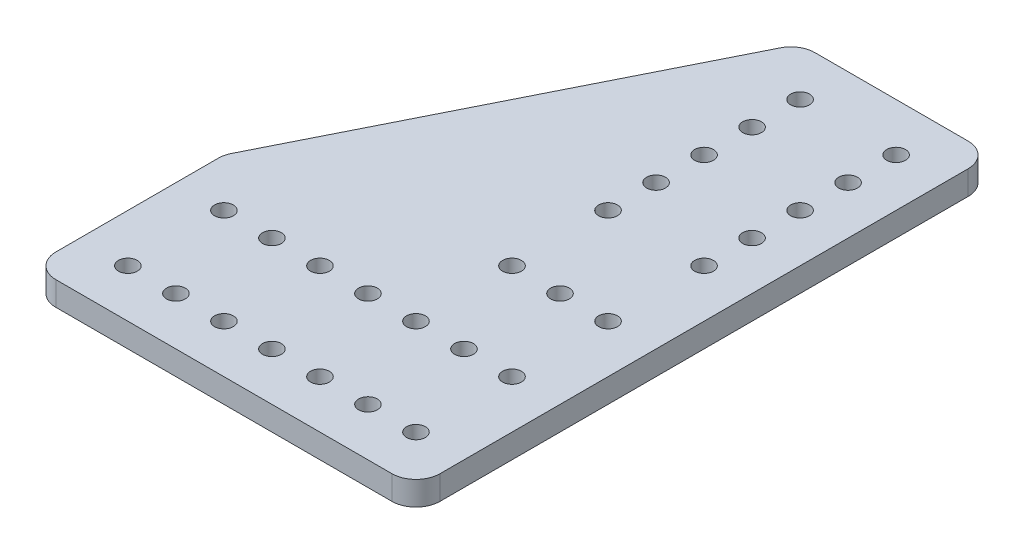
from build123d import *

# Parameters (mm, degrees)
BOSS_EXTRUDE1_DEPTH = 6.35
SKETCH2_R           = 2.4892
CUT_EXTRUDE1_DEPTH  = 7.35
FILLET1_R           = 6.35


with BuildPart() as part:
    # Sketch1 → Boss-Extrude1 (new body)
    with BuildSketch(Plane(origin=(0, 0, 0), x_dir=(1, 0, 0), z_dir=(0, 1, 0))):
        Polygon((0, 50.8), (50.8, 152.4), (101.6, 152.4), (101.6, 0), (0, 0), align=None)
    extrude(amount=BOSS_EXTRUDE1_DEPTH)

    # Sketch2 → Cut-Extrude1 (cut, through all)
    with BuildSketch(Plane(origin=(0, 6.35, 0), x_dir=(1, 0, 0), z_dir=(0, 1, 0))):
        with Locations((88.9, 12.7)):
            Circle(SKETCH2_R)
        with Locations((76.2, 12.7)):
            Circle(SKETCH2_R)
        with Locations((63.5, 12.7)):
            Circle(SKETCH2_R)
        with Locations((50.8, 12.7)):
            Circle(SKETCH2_R)
        with Locations((38.1, 12.7)):
            Circle(SKETCH2_R)
        with Locations((25.4, 12.7)):
            Circle(SKETCH2_R)
        with Locations((12.7, 12.7)):
            Circle(SKETCH2_R)
        with Locations((76.2, 38.1)):
            Circle(SKETCH2_R)
        with Locations((63.5, 38.1)):
            Circle(SKETCH2_R)
        with Locations((50.8, 38.1)):
            Circle(SKETCH2_R)
        with Locations((38.1, 38.1)):
            Circle(SKETCH2_R)
        with Locations((25.4, 38.1)):
            Circle(SKETCH2_R)
        with Locations((12.7, 38.1)):
            Circle(SKETCH2_R)
        with Locations((76.2, 63.5)):
            Circle(SKETCH2_R)
        with Locations((63.5, 63.5)):
            Circle(SKETCH2_R)
        with Locations((63.5, 88.9)):
            Circle(SKETCH2_R)
        with Locations((63.5, 101.6)):
            Circle(SKETCH2_R)
        with Locations((63.5, 114.3)):
            Circle(SKETCH2_R)
        with Locations((63.5, 127)):
            Circle(SKETCH2_R)
        with Locations((63.5, 139.7)):
            Circle(SKETCH2_R)
        with Locations((88.9, 38.1)):
            Circle(SKETCH2_R)
        with Locations((88.9, 63.5)):
            Circle(SKETCH2_R)
        with Locations((88.9, 88.9)):
            Circle(SKETCH2_R)
        with Locations((88.9, 101.6)):
            Circle(SKETCH2_R)
        with Locations((88.9, 114.3)):
            Circle(SKETCH2_R)
        with Locations((88.9, 127)):
            Circle(SKETCH2_R)
        with Locations((88.9, 139.7)):
            Circle(SKETCH2_R)
    extrude(amount=-CUT_EXTRUDE1_DEPTH, mode=Mode.SUBTRACT)

    # Fillet1
    fillet1_edges = [part.edges().sort_by_distance(p)[0] for p in [
        (0, 3.175, -50.8),
        (50.8, 3.175, -152.4),
        (101.6, 3.175, -152.4),
        (101.6, 3.175, 0),
        (0, 3.175, 0),
    ]]
    fillet(fillet1_edges, radius=FILLET1_R)


solid = part.part
